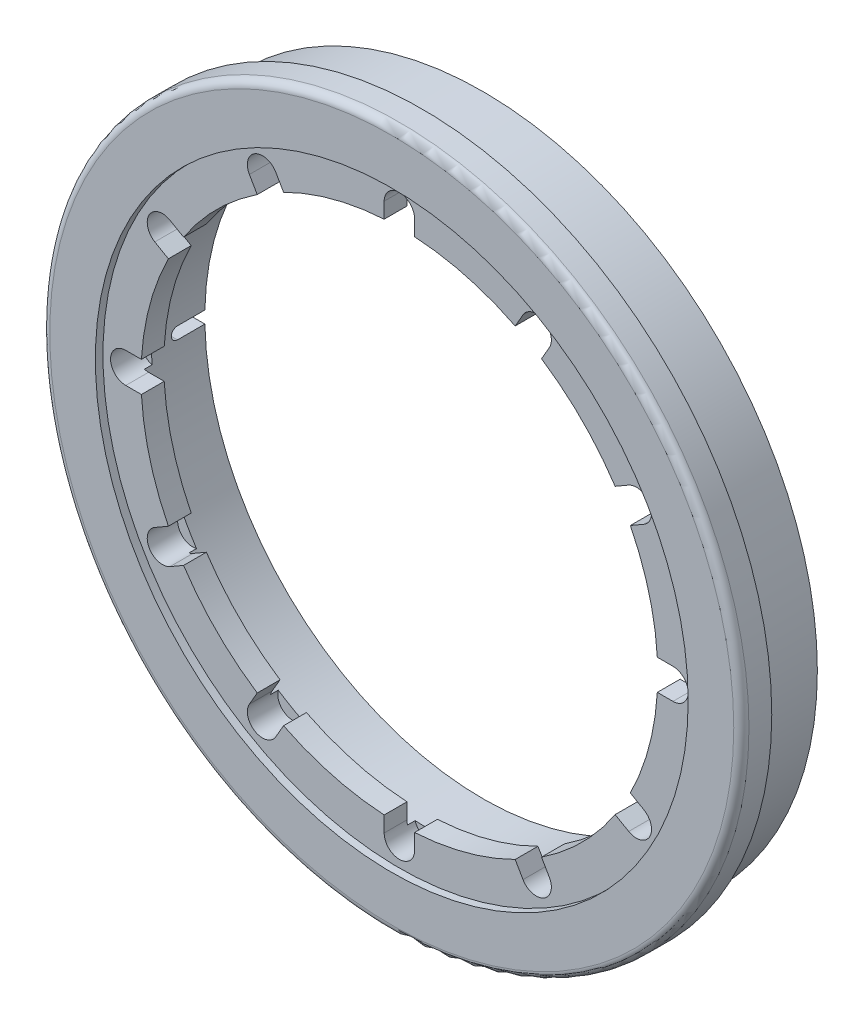
from build123d import *

# Parameters (mm, degrees)
ESQUISSE1_R                  = 22
ESQUISSE1_R_2                = 18.3
BOSS_EXTRU_1_DEPTH           = 4
ESQUISSE2_R                  = 23
ESQUISSE2_R_2                = 19.5
BOSS_EXTRU_2_DEPTH           = 2
CONG_1_R                     = 0.5
ENL_V_MAT_EXTRU_1_REACH      = 25
ESQUISSE4_R                  = 19.5
ESQUISSE4_R_2                = 17
BOSS_EXTRU_3_DEPTH           = 1.5
ENL_V_MAT_EXTRU_2_DEPTH      = 2
R_P_TITION_CIRCULAIRE1_COUNT = 12


with BuildPart() as part:
    # Esquisse1 → Boss.-Extru.1 (new body)
    with BuildSketch(Plane.XY):
        Circle(ESQUISSE1_R)
        Circle(ESQUISSE1_R_2, mode=Mode.SUBTRACT)
    extrude(amount=BOSS_EXTRU_1_DEPTH)

    # Esquisse2 → Boss.-Extru.2 (add)
    with BuildSketch(Plane.XY.offset(4)):
        Circle(ESQUISSE2_R)
        Circle(ESQUISSE2_R_2, mode=Mode.SUBTRACT)
    extrude(amount=BOSS_EXTRU_2_DEPTH)

    # Congé1
    cong_1_edges = [part.edges().sort_by_distance(p)[0] for p in [
        (-23, 0, 6),
    ]]
    fillet(cong_1_edges, radius=CONG_1_R)

    # Esquisse3 → Enlèv. mat.-Extru.1 (cut, up to next)
    with BuildSketch(Plane(origin=(0, 0, 0), x_dir=(0, 0, -1), z_dir=(1, 0, 0)), mode=Mode.PRIVATE) as enl_v_mat_extru_1_sk1:
        with BuildLine():
            Line((0, -0.4), (-1.8, -0.4))
            ThreePointArc((-1.8, -0.4), (-2.2, 0), (-1.8, 0.4))
            Line((-1.8, 0.4), (0, 0.4))
            ThreePointArc((0, 0.4), (0.4, 0), (0, -0.4))
        make_face()
    enl_v_mat_extru_1_tool1 = extrude(enl_v_mat_extru_1_sk1.sketch, amount=-ENL_V_MAT_EXTRU_1_REACH, mode=Mode.PRIVATE) & part.part
    add(enl_v_mat_extru_1_tool1.solids().sort_by_distance((0, 0, 0.9))[0], mode=Mode.SUBTRACT)

    # Esquisse4 → Boss.-Extru.3 (add)
    with BuildSketch(Plane.XY.offset(4)):
        Circle(ESQUISSE4_R)
        Circle(ESQUISSE4_R_2, mode=Mode.SUBTRACT)
    extrude(amount=BOSS_EXTRU_3_DEPTH)

    # Esquisse5 → Enlèv. mat.-Extru.2 (cut)
    with BuildSketch(Plane.XY.offset(5.5)):
        with BuildLine():
            Line((-1, 15.094284231), (-1, 18))
            ThreePointArc((-1, 18), (0, 19), (1, 18))
            Line((1, 18), (1, 15.094284231))
            ThreePointArc((1, 15.094284231), (0, 14.094284231), (-1, 15.094284231))
        make_face()
    enl_v_mat_extru_2 = extrude(amount=-ENL_V_MAT_EXTRU_2_DEPTH, mode=Mode.SUBTRACT)

    # Répétition circulaire1: Enlèv. mat.-Extru.2 ×12 about axis
    r_p_tition_circulaire1_axis = Axis((0, 0, 0), (0, 0, 1))
    for i in range(1, R_P_TITION_CIRCULAIRE1_COUNT):
        add(enl_v_mat_extru_2.rotate(r_p_tition_circulaire1_axis, i * 360 / R_P_TITION_CIRCULAIRE1_COUNT), mode=Mode.SUBTRACT)


solid = part.part
